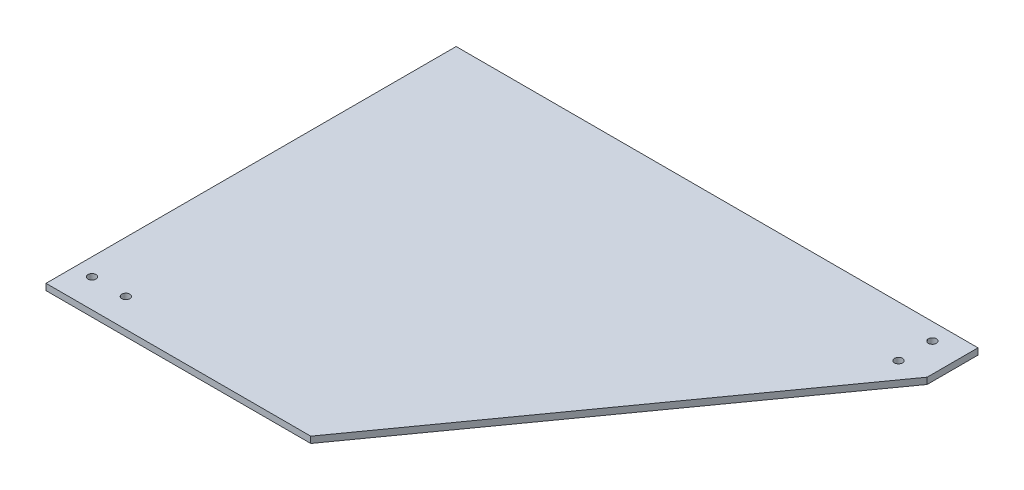
from build123d import *

# Parameters (mm, degrees)
SKETCH1_R           = 1.8923
BOSS_EXTRUDE1_DEPTH = 3


with BuildPart() as part:
    # Sketch1 → Boss-Extrude1 (new body)
    with BuildSketch(Plane(origin=(0, 0, 0), x_dir=(1, 0, 0), z_dir=(0, 1, 0))):
        Polygon((-123.2, 0), (123.2, 0), (123.2, -24), (1.8, -193.652), (-123.2, -193.652), align=None)
        with Locations((-99, -180.152)):
            Circle(SKETCH1_R, mode=Mode.SUBTRACT)
        with Locations((109.675, -8)):
            Circle(SKETCH1_R, mode=Mode.SUBTRACT)
        with Locations((-115, -180.152)):
            Circle(SKETCH1_R, mode=Mode.SUBTRACT)
        with Locations((109.675, -24)):
            Circle(SKETCH1_R, mode=Mode.SUBTRACT)
    extrude(amount=BOSS_EXTRUDE1_DEPTH)


solid = part.part
